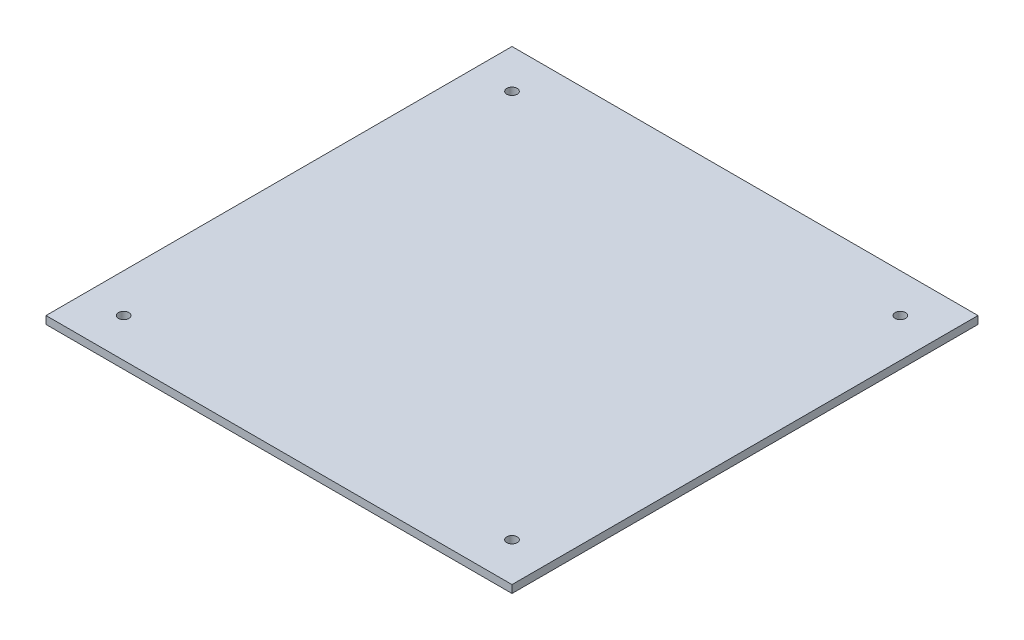
from build123d import *

# Parameters (mm, degrees)
SKETCH1_W           = 180
SKETCH1_H           = 180
SKETCH1_R           = 2
BOSS_EXTRUDE1_DEPTH = 3


with BuildPart() as part:
    # Sketch1 → Boss-Extrude1 (new body)
    with BuildSketch(Plane(origin=(0, 0, 0), x_dir=(1, 0, 0), z_dir=(0, 1, 0))):
        Rectangle(SKETCH1_W, SKETCH1_H)
        with Locations((-75, 75)):
            Circle(SKETCH1_R, mode=Mode.SUBTRACT)
        with Locations((75, 75)):
            Circle(SKETCH1_R, mode=Mode.SUBTRACT)
        with Locations((-75, -75)):
            Circle(SKETCH1_R, mode=Mode.SUBTRACT)
        with Locations((75, -75)):
            Circle(SKETCH1_R, mode=Mode.SUBTRACT)
    extrude(amount=BOSS_EXTRUDE1_DEPTH)


solid = part.part
